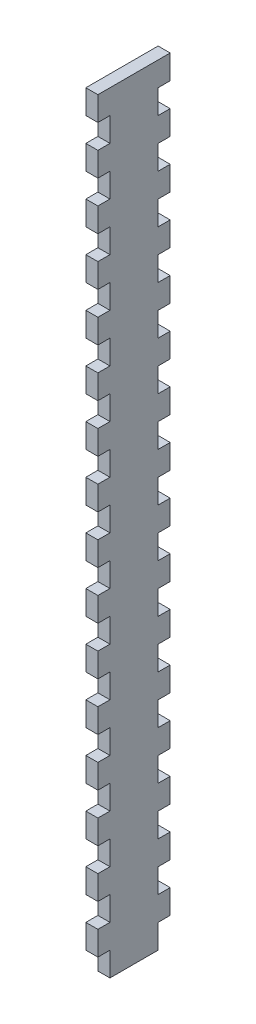
from build123d import *

# Parameters (mm, degrees)
SKETCH1_W           = 38.1
SKETCH1_H           = 406.4
BOSS_EXTRUDE1_DEPTH = 6.35
SKETCH2_W           = 6.35
SKETCH2_H           = 12.7
CUT_EXTRUDE1_DEPTH  = 7.35
LPATTERN1_COUNT     = 16
LPATTERN1_PITCH     = 25.4


with BuildPart() as part:
    # Sketch1 → Boss-Extrude1 (new body)
    with BuildSketch(Plane(origin=(0, 0, 0), x_dir=(0, 0, -1), z_dir=(1, 0, 0))):
        with Locations((19.05, 203.2)):
            Rectangle(SKETCH1_W, SKETCH1_H)
    extrude(amount=BOSS_EXTRUDE1_DEPTH)

    # Sketch2 → Cut-Extrude1 (cut, through all)
    with BuildSketch(Plane(origin=(6.35, 0, 0), x_dir=(0, 0, -1), z_dir=(1, 0, 0))):
        with Locations((3.175, 6.35)):
            Rectangle(SKETCH2_W, SKETCH2_H)
        with Locations((34.925, 6.35)):
            Rectangle(SKETCH2_W, SKETCH2_H)
    cut_extrude1 = extrude(amount=-CUT_EXTRUDE1_DEPTH, mode=Mode.SUBTRACT)

    # LPattern1: Cut-Extrude1 ×16
    with Locations(*[(0, i * LPATTERN1_PITCH, 0) for i in range(1, LPATTERN1_COUNT)]):
        add(cut_extrude1, mode=Mode.SUBTRACT)


solid = part.part
